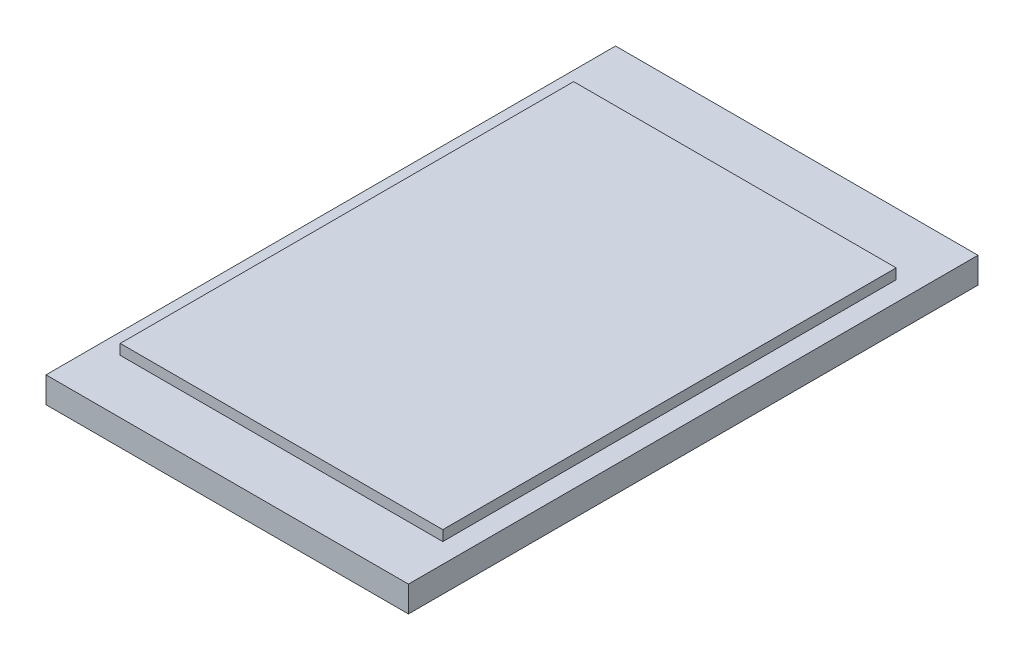
from build123d import *

# Parameters (mm, degrees)
SKETCH1_W           = 70
SKETCH1_H           = 110
BOSS_EXTRUDE1_DEPTH = 5
SKETCH2_W           = 62.290535519
SKETCH2_H           = 87.567854281
BOSS_EXTRUDE2_DEPTH = 2


with BuildPart() as part:
    # Sketch1 → Boss-Extrude1 (new body)
    with BuildSketch(Plane(origin=(0, 0, 0), x_dir=(1, 0, 0), z_dir=(0, 1, 0))):
        with Locations((-44.029126214, 9.077669903)):
            Rectangle(SKETCH1_W, SKETCH1_H)
    extrude(amount=BOSS_EXTRUDE1_DEPTH)

    # Sketch2 → Boss-Extrude2 (add)
    with BuildSketch(Plane(origin=(0, 5, 0), x_dir=(1, 0, 0), z_dir=(0, 1, 0))):
        with Locations((-43.972847259, 8.287753692)):
            Rectangle(SKETCH2_W, SKETCH2_H)
    extrude(amount=BOSS_EXTRUDE2_DEPTH)


solid = part.part
